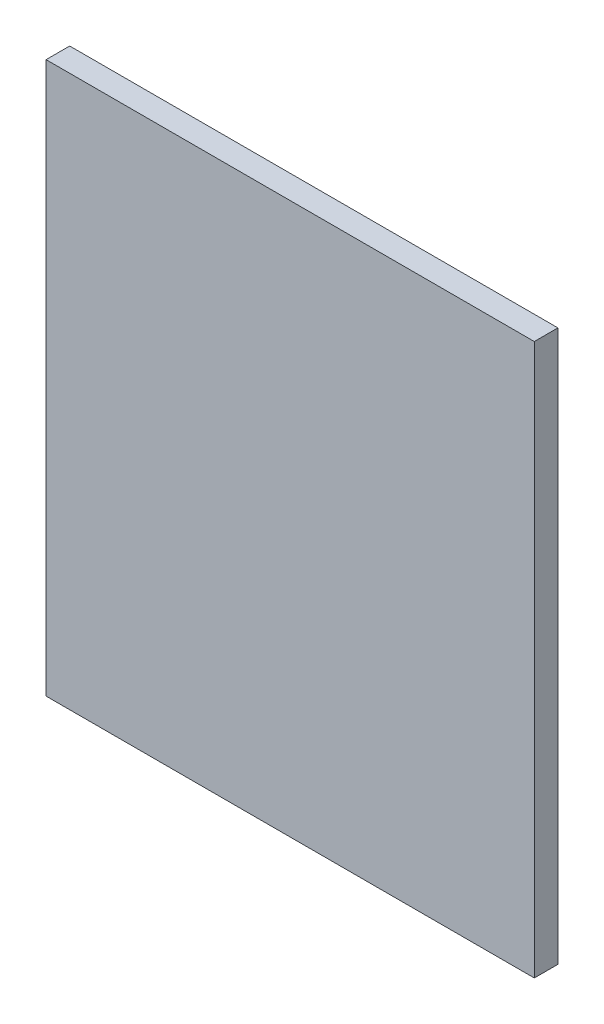
from build123d import *

# Parameters (mm, degrees)
ESQUISSE1_W        = 310
ESQUISSE1_H        = 350
BOSS_EXTRU_1_DEPTH = 15


with BuildPart() as part:
    # Esquisse1 → Boss.-Extru.1 (new body)
    with BuildSketch(Plane.XY):
        Rectangle(ESQUISSE1_W, ESQUISSE1_H)
    extrude(amount=BOSS_EXTRU_1_DEPTH)


solid = part.part
